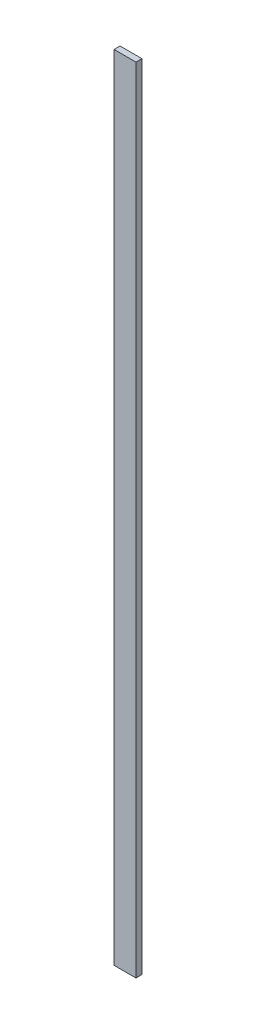
from build123d import *

# Parameters (mm, degrees)
SKETCH1_W           = 139.7
SKETCH1_H           = 38.1
BOSS_EXTRUDE1_DEPTH = 5054.6


with BuildPart() as part:
    # Sketch1 → Boss-Extrude1 (new body)
    with BuildSketch(Plane(origin=(0, 0, 0), x_dir=(1, 0, 0), z_dir=(0, 1, 0))):
        Rectangle(SKETCH1_W, SKETCH1_H)
    extrude(amount=BOSS_EXTRUDE1_DEPTH)


solid = part.part
